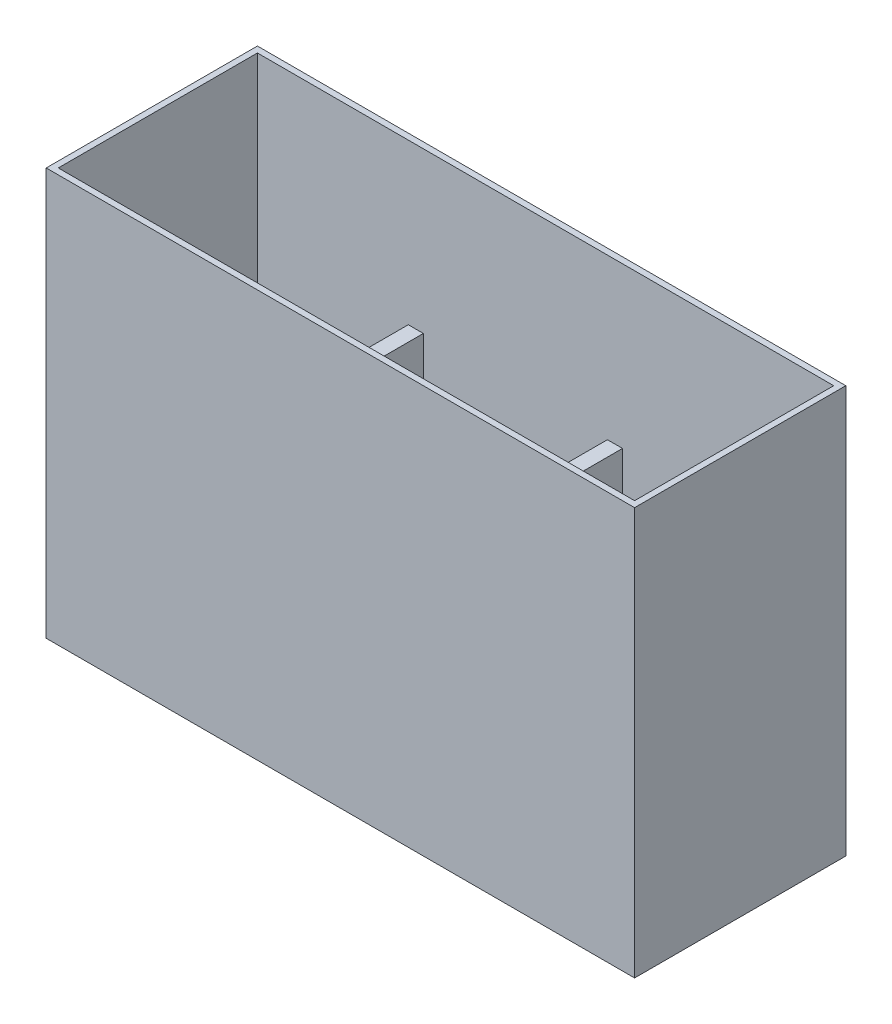
from build123d import *

# Parameters (mm, degrees)
SKETCH1_W           = 247.65
SKETCH1_H           = 88.9
BOSS_EXTRUDE1_DEPTH = 171.45
SHELL1_T            = -2.54
BOSS_EXTRUDE2_DEPTH = 101.6
CUT_EXTRUDE1_REACH  = 23.59
SKETCH4_R           = 25.4
SKETCH5_W           = 6.35
SKETCH5_H           = 64.77
SKETCH5_H_2         = 83.82
BOSS_EXTRUDE3_DEPTH = 101.6


with BuildPart() as part:
    # Sketch1 → Boss-Extrude1 (new body)
    with BuildSketch(Plane(origin=(0, 0, 0), x_dir=(1, 0, 0), z_dir=(0, 1, 0))):
        with Locations((123.825, -44.45)):
            Rectangle(SKETCH1_W, SKETCH1_H)
    extrude(amount=BOSS_EXTRUDE1_DEPTH)

    # Shell1
    shell1_openings = [part.faces().sort_by_distance(p)[0] for p in [
        (123.825, 171.45, 44.45),
    ]]
    offset(amount=SHELL1_T, openings=shell1_openings, kind=Kind.INTERSECTION)

    # Sketch2 → Boss-Extrude2 (add)
    with BuildSketch(Plane(origin=(0, 2.54, 0), x_dir=(1, 0, 0), z_dir=(0, 1, 0))):
        Polygon((245.11, -73.66), (156.21, -73.66), (156.21, -86.36), (149.86, -86.36), (149.86, -67.31), (245.11, -67.31), align=None)
    extrude(amount=BOSS_EXTRUDE2_DEPTH)

    # Sketch4 → Cut-Extrude1 (cut, up to next)
    with BuildSketch(Plane(origin=(0, 0, 67.31), x_dir=(-1, 0, 0), z_dir=(0, 0, -1)), mode=Mode.PRIVATE) as cut_extrude1_sk1:
        with Locations((-197.485, 104.14)):
            Circle(SKETCH4_R)
    cut_extrude1_tool1 = extrude(cut_extrude1_sk1.sketch, amount=-CUT_EXTRUDE1_REACH, mode=Mode.PRIVATE) & part.part
    add(cut_extrude1_tool1.solids().sort_by_distance((197.485, 104.14, 67.31))[0], mode=Mode.SUBTRACT)

    # Sketch5 → Boss-Extrude3 (add)
    with BuildSketch(Plane(origin=(0, 2.54, 0), x_dir=(1, 0, 0), z_dir=(0, 1, 0))):
        with Locations((153.035, -34.925)):
            Rectangle(SKETCH5_W, SKETCH5_H)
        with Locations((69.215, -44.45)):
            Rectangle(SKETCH5_W, SKETCH5_H_2)
    extrude(amount=BOSS_EXTRUDE3_DEPTH)


solid = part.part
